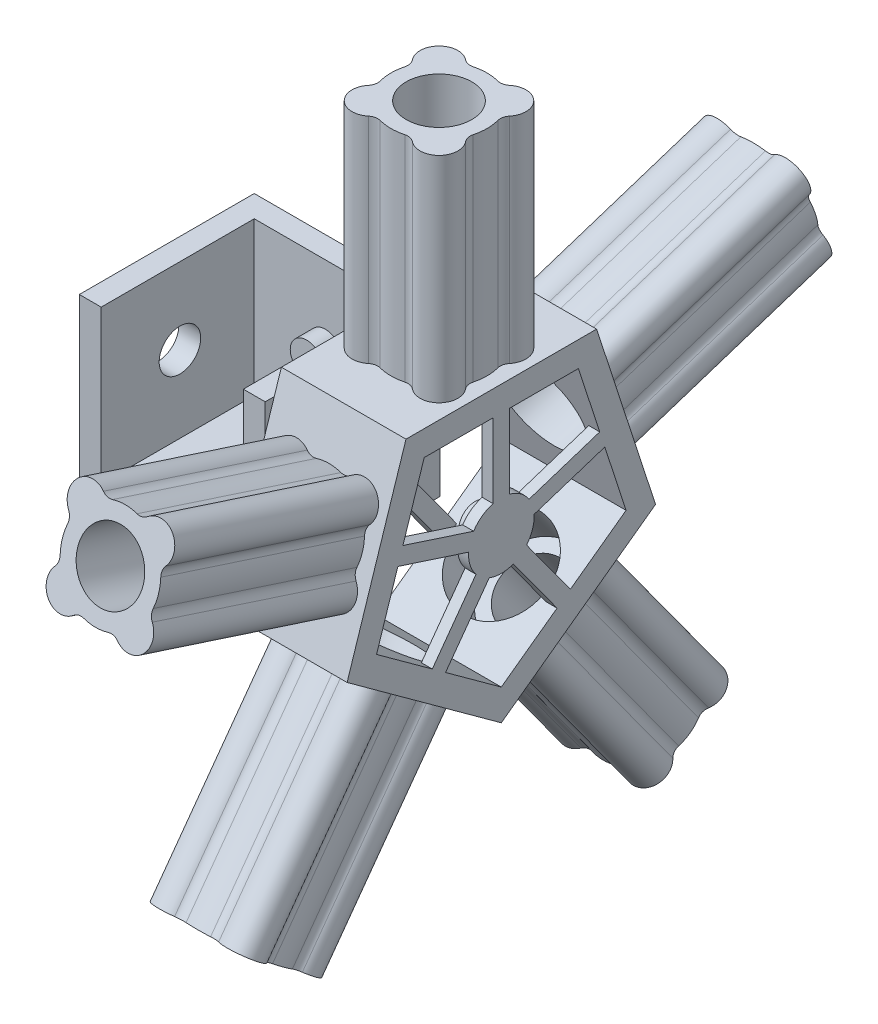
from build123d import *

# Parameters (mm, degrees)
SKETCH1_W            = 85
SKETCH1_H            = 80
BOSS_EXTRUDE1_DEPTH  = 7.5
BOSS_EXTRUDE2_DEPTH  = 70
SKETCH3_R            = 7.5
BOSS_EXTRUDE3_DEPTH  = 8.54
SKETCH4_R            = 9.5
CUT_EXTRUDE1_DEPTH   = 15
SKETCH5_R            = 7.49999607
CUT_EXTRUDE2_DEPTH   = 15
SKETCH6_R            = 10
SKETCH6_R_2          = 7.49999607
BOSS_EXTRUDE4_DEPTH  = 15
SKETCH7_R            = 7.49999607
BOSS_EXTRUDE7_DEPTH  = 5
BOSS_EXTRUDE14_DEPTH = 47
BOSS_EXTRUDE15_DEPTH = 5
SKETCH13_R           = 7.499996074
BOSS_EXTRUDE16_DEPTH = 7
SKETCH14_R           = 15
BOSS_EXTRUDE17_DEPTH = 98
SKETCH15_R           = 15
CUT_EXTRUDE3_DEPTH   = 12
CIRPATTERN1_COUNT    = 5
SKETCH16_R           = 21
CUT_EXTRUDE4_DEPTH   = 25
CIRPATTERN2_COUNT    = 5


with BuildPart() as part:
    # Sketch1 → Boss-Extrude1 (new body)
    with BuildSketch(Plane(origin=(0, 0, 0), x_dir=(1, 0, 0), z_dir=(0, 1, 0))):
        with Locations((42.5, 40)):
            Rectangle(SKETCH1_W, SKETCH1_H)
    extrude(amount=BOSS_EXTRUDE1_DEPTH)

    # Sketch2 → Boss-Extrude2 (add)
    with BuildSketch(Plane(origin=(0, 7.5, 0), x_dir=(1, 0, 0), z_dir=(0, 1, 0))):
        Polygon((0, 0), (0, 80), (85, 80), (85, 0), (75, 0), (74.999999971, 69.998071514), (10, 70), (10, 0), align=None)
    extrude(amount=BOSS_EXTRUDE2_DEPTH)

    # Sketch3 → Boss-Extrude3 (add)
    with BuildSketch(Plane(origin=(0.00207684, 0, -70.000296629), x_dir=(0.999999999559875, 0, 2.9669014309230413e-05), z_dir=(-2.9669014309230413e-05, 0, 0.999999999559875))):
        with Locations(Location((42.497923165, 42.5, 0), (0, 0, 180))):
            Circle(SKETCH3_R)
    extrude(amount=BOSS_EXTRUDE3_DEPTH)

    # Sketch4 → Cut-Extrude1 (cut)
    with BuildSketch(Plane(origin=(10, 0, 0), x_dir=(0, 0, -1), z_dir=(1, 0, 0))):
        with Locations((36, 42.5)):
            Circle(SKETCH4_R)
    extrude(amount=-CUT_EXTRUDE1_DEPTH, mode=Mode.SUBTRACT)

    # Sketch5 → Cut-Extrude2 (cut)
    with BuildSketch(Plane.ZY.offset(-75)):
        with Locations((-36, 42.5)):
            Circle(SKETCH5_R)
    extrude(amount=-CUT_EXTRUDE2_DEPTH, mode=Mode.SUBTRACT)

    # Sketch6 → Boss-Extrude4 (add)
    with BuildSketch(Plane(origin=(85, 0, 0), x_dir=(0, 0, -1), z_dir=(1, 0, 0))):
        with Locations(Location((36.000000035, 42.5, 0), (0, 0, 180))):
            Circle(SKETCH6_R)
        with Locations(Location((36.000000035, 42.5, 0), (0, 0, 180))):
            Circle(SKETCH6_R_2, mode=Mode.SUBTRACT)
    extrude(amount=BOSS_EXTRUDE4_DEPTH)

    # Sketch7 → Boss-Extrude7 (add)
    with BuildSketch(Plane(origin=(100, 0, 0), x_dir=(0, 0, -1), z_dir=(1, 0, 0))):
        Polygon((-7.592551646, 102.5), (-34.53423024, 19.582039325), (36.000000035, -31.66407865), (106.53423031, 19.582039325), (79.592551715, 102.5), align=None)
        with Locations(Location((36.000000035, 42.5, 0), (0, 0, 180))):
            Circle(SKETCH7_R, mode=Mode.SUBTRACT)
        with BuildLine():
            Line((81.006439363, 61.066461936), (48.654033989, 50.55452821))
            ThreePointArc((48.654033989, 50.55452821), (44.816778819, 54.635254916), (39.750000035, 57.023687548))
            Line((39.750000035, 57.023687548), (39.750000035, 91.041019662))
            Line((39.750000035, 91.041019662), (71.267115172, 91.041019662))
            Line((71.267115172, 91.041019662), (81.006439363, 61.066461936))
        make_face(mode=Mode.SUBTRACT)
        with BuildLine():
            Line((0.732884897, 91.041019662), (-9.006439294, 61.066461936))
            Line((-9.006439294, 61.066461936), (23.34596608, 50.55452821))
            ThreePointArc((23.34596608, 50.55452821), (27.18322125, 54.635254916), (32.250000035, 57.023687548))
            Line((32.250000035, 57.023687548), (32.250000035, 91.041019662))
            Line((32.250000035, 91.041019662), (0.732884897, 91.041019662))
        make_face(mode=Mode.SUBTRACT)
        with BuildLine():
            Line((-21.063390943, 23.958980338), (4.434490817, 5.433684865))
            Line((4.434490817, 5.433684865), (24.429376956, 32.954284649))
            ThreePointArc((24.429376956, 32.954284649), (21.73415229, 37.864745084), (21.028338622, 43.421604337))
            Line((21.028338622, 43.421604337), (-11.324066752, 53.933538064))
            Line((-11.324066752, 53.933538064), (-21.063390943, 23.958980338))
        make_face(mode=Mode.SUBTRACT)
        with BuildLine():
            Line((36.000000035, -17.5), (61.497881795, 1.025295473))
            Line((61.497881795, 1.025295473), (41.502995656, 28.545895256))
            ThreePointArc((41.502995656, 28.545895256), (36.000000035, 27.5), (30.497004414, 28.545895256))
            Line((30.497004414, 28.545895256), (10.502118275, 1.025295473))
            Line((10.502118275, 1.025295473), (36.000000035, -17.5))
        make_face(mode=Mode.SUBTRACT)
        with BuildLine():
            Line((93.063391012, 23.958980338), (83.324066821, 53.933538064))
            Line((83.324066821, 53.933538064), (50.971661447, 43.421604337))
            ThreePointArc((50.971661447, 43.421604337), (50.265847779, 37.864745084), (47.570623113, 32.954284649))
            Line((47.570623113, 32.954284649), (67.565509253, 5.433684865))
            Line((67.565509253, 5.433684865), (93.063391012, 23.958980338))
        make_face(mode=Mode.SUBTRACT)
    extrude(amount=BOSS_EXTRUDE7_DEPTH)

    # Sketch11 → Boss-Extrude14 (add)
    with BuildSketch(Plane(origin=(105, 0, 0), x_dir=(0, 0, -1), z_dir=(1, 0, 0))):
        Polygon((79.592551715, 102.5), (-7.592551646, 102.5), (-34.53423024, 19.582039325), (36.000000035, -31.66407865), (106.53423031, 19.582039325), align=None)
        Polygon((71.267115172, 91.041019662), (0.732884897, 91.041019662), (-21.063390943, 23.958980338), (36.000000035, -17.5), (93.063391012, 23.958980338), align=None, mode=Mode.SUBTRACT)
    extrude(amount=BOSS_EXTRUDE14_DEPTH)

    # Sketch12 → Boss-Extrude15 (add)
    with BuildSketch(Plane(origin=(152, 0, 0), x_dir=(0, 0, -1), z_dir=(1, 0, 0))):
        Polygon((79.592551715, 102.5), (-7.592551646, 102.5), (-34.53423024, 19.582039325), (36.000000035, -31.66407865), (106.53423031, 19.582039325), align=None)
        with BuildLine():
            Line((0.732884897, 91.041019662), (32.250000035, 91.041019662))
            Line((32.250000035, 91.041019662), (32.250000035, 57.023687548))
            ThreePointArc((32.250000035, 57.023687548), (27.18322125, 54.635254916), (23.34596608, 50.55452821))
            Line((23.34596608, 50.55452821), (-9.006439294, 61.066461936))
            Line((-9.006439294, 61.066461936), (0.732884897, 91.041019662))
        make_face(mode=Mode.SUBTRACT)
        with BuildLine():
            Line((39.750000035, 57.023687548), (39.750000035, 91.041019662))
            Line((39.750000035, 91.041019662), (71.267115172, 91.041019662))
            Line((71.267115172, 91.041019662), (81.006439363, 61.066461936))
            Line((81.006439363, 61.066461936), (48.654033989, 50.55452821))
            ThreePointArc((48.654033989, 50.55452821), (44.816778819, 54.635254916), (39.750000035, 57.023687548))
        make_face(mode=Mode.SUBTRACT)
        with BuildLine():
            Line((50.971661447, 43.421604337), (83.324066821, 53.933538064))
            Line((83.324066821, 53.933538064), (93.063391012, 23.958980338))
            Line((93.063391012, 23.958980338), (67.565509253, 5.433684865))
            Line((67.565509253, 5.433684865), (47.570623113, 32.954284649))
            ThreePointArc((47.570623113, 32.954284649), (50.265847779, 37.864745084), (50.971661447, 43.421604337))
        make_face(mode=Mode.SUBTRACT)
        with BuildLine():
            Line((41.502995656, 28.545895256), (61.497881795, 1.025295473))
            Line((61.497881795, 1.025295473), (36.000000035, -17.5))
            Line((36.000000035, -17.5), (10.502118275, 1.025295473))
            Line((10.502118275, 1.025295473), (30.497004414, 28.545895256))
            ThreePointArc((30.497004414, 28.545895256), (36.000000035, 27.5), (41.502995656, 28.545895256))
        make_face(mode=Mode.SUBTRACT)
        with BuildLine():
            Line((21.028338622, 43.421604337), (-11.324066752, 53.933538064))
            Line((-11.324066752, 53.933538064), (-21.063390943, 23.958980338))
            Line((-21.063390943, 23.958980338), (4.434490817, 5.433684865))
            Line((4.434490817, 5.433684865), (24.429376956, 32.954284649))
            ThreePointArc((24.429376956, 32.954284649), (21.73415229, 37.864745084), (21.028338622, 43.421604337))
        make_face(mode=Mode.SUBTRACT)
    extrude(amount=BOSS_EXTRUDE15_DEPTH)

    # Sketch13 → Boss-Extrude16 (add)
    with BuildSketch(Plane.ZY.offset(-152)):
        with Locations((-36.000000035, 42.5)):
            Circle(SKETCH13_R)
    extrude(amount=BOSS_EXTRUDE16_DEPTH)

    # Sketch14 → Boss-Extrude17 (add)
    with BuildSketch(Plane(origin=(0, 102.5, 0), x_dir=(1, 0, 0), z_dir=(0, 1, 0))):
        with BuildLine():
            ThreePointArc((122.883888228, 14.728909593), (128.5, 14.000000035), (134.116111772, 14.728909593))
            ThreePointArc((134.116111772, 14.728909593), (136.457902326, 14.779744304), (138.565877002, 13.758465725))
            ThreePointArc((138.565877002, 13.758465725), (150.173414861, 14.326585174), (150.741534309, 25.934123033))
            ThreePointArc((150.741534309, 25.934123033), (149.72025573, 28.042097708), (149.771090441, 30.383888262))
            ThreePointArc((149.771090441, 30.383888262), (150.5, 36.000000035), (149.771090441, 41.616111807))
            ThreePointArc((149.771090441, 41.616111807), (149.72025573, 43.957902361), (150.741534309, 46.065877036))
            ThreePointArc((150.741534309, 46.065877036), (150.173414861, 57.673414896), (138.565877002, 58.241534344))
            ThreePointArc((138.565877002, 58.241534344), (136.457902326, 57.220255765), (134.116111772, 57.271090476))
            ThreePointArc((134.116111772, 57.271090476), (128.5, 58.000000035), (122.883888228, 57.271090476))
            ThreePointArc((122.883888228, 57.271090476), (120.542097674, 57.220255765), (118.434122998, 58.241534344))
            ThreePointArc((118.434122998, 58.241534344), (106.826585139, 57.673414896), (106.258465691, 46.065877036))
            ThreePointArc((106.258465691, 46.065877036), (107.27974427, 43.957902361), (107.228909559, 41.616111807))
            ThreePointArc((107.228909559, 41.616111807), (106.5, 36.000000035), (107.228909559, 30.383888262))
            ThreePointArc((107.228909559, 30.383888262), (107.27974427, 28.042097708), (106.258465691, 25.934123033))
            ThreePointArc((106.258465691, 25.934123033), (106.826585139, 14.326585174), (118.434122998, 13.758465725))
            ThreePointArc((118.434122998, 13.758465725), (120.542097674, 14.779744304), (122.883888228, 14.728909593))
        make_face()
        with Locations(Location((128.5, 36.000000035, 0), (0, 0, 270))):
            Circle(SKETCH14_R, mode=Mode.SUBTRACT)
    boss_extrude17 = extrude(amount=BOSS_EXTRUDE17_DEPTH)

    # Sketch15 → Cut-Extrude3 (cut)
    with BuildSketch(Plane(origin=(0, 102.5, 0), x_dir=(1, 0, 0), z_dir=(0, 1, 0))):
        with Locations(Location((128.5, 36.000000035, 0), (0, 0, 90))):
            Circle(SKETCH15_R)
    cut_extrude3 = extrude(amount=-CUT_EXTRUDE3_DEPTH, mode=Mode.SUBTRACT)

    # CirPattern1: Boss-Extrude17, Cut-Extrude3 ×5 about axis
    cirpattern1_axis = Axis((0, 42.5, -36.000000035), (1, 0, 0))
    add([boss_extrude17.rotate(cirpattern1_axis, i * 360 / CIRPATTERN1_COUNT) for i in range(1, CIRPATTERN1_COUNT)])
    add([cut_extrude3.rotate(cirpattern1_axis, i * 360 / CIRPATTERN1_COUNT) for i in range(1, CIRPATTERN1_COUNT)], mode=Mode.SUBTRACT)

    # Sketch16 → Cut-Extrude4 (cut)
    with BuildSketch(Plane(origin=(0, 91.041019662, 0), x_dir=(-1, 0, 0), z_dir=(0, -1, 0))):
        with Locations(Location((-128.5, 36.000000035, 0), (0, 0, 90))):
            Circle(SKETCH16_R)
    cut_extrude4 = extrude(amount=-CUT_EXTRUDE4_DEPTH, mode=Mode.SUBTRACT)

    # CirPattern2: Cut-Extrude4 ×5 about axis
    cirpattern2_axis = Axis((0, 42.5, -36.000000035), (1, 0, 0))
    for i in range(1, CIRPATTERN2_COUNT):
        add(cut_extrude4.rotate(cirpattern2_axis, i * 360 / CIRPATTERN2_COUNT), mode=Mode.SUBTRACT)


solid = part.part
